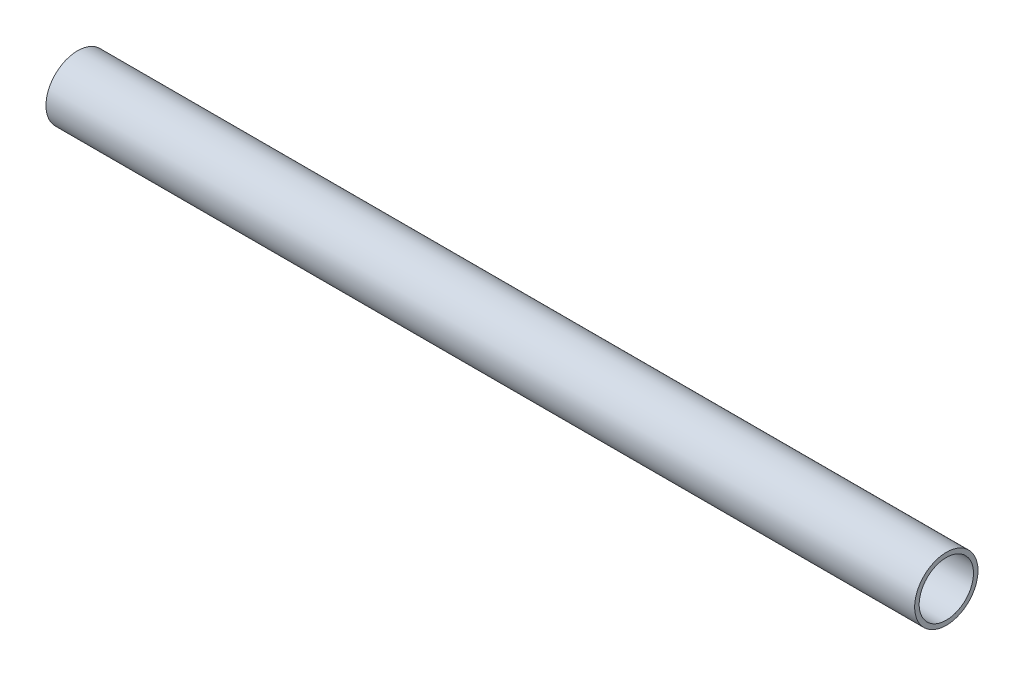
from build123d import *

# Parameters (mm, degrees)
SKETCH1_R           = 44.45
SKETCH1_R_2         = 38.1
BOSS_EXTRUDE1_DEPTH = 609.6


with BuildPart() as part:
    # Sketch1 → Boss-Extrude1 (new body, symmetric)
    with BuildSketch(Plane(origin=(0, 0, 0), x_dir=(0, 0, -1), z_dir=(1, 0, 0))):
        Circle(SKETCH1_R)
        Circle(SKETCH1_R_2, mode=Mode.SUBTRACT)
    extrude(amount=BOSS_EXTRUDE1_DEPTH, both=True)


solid = part.part
